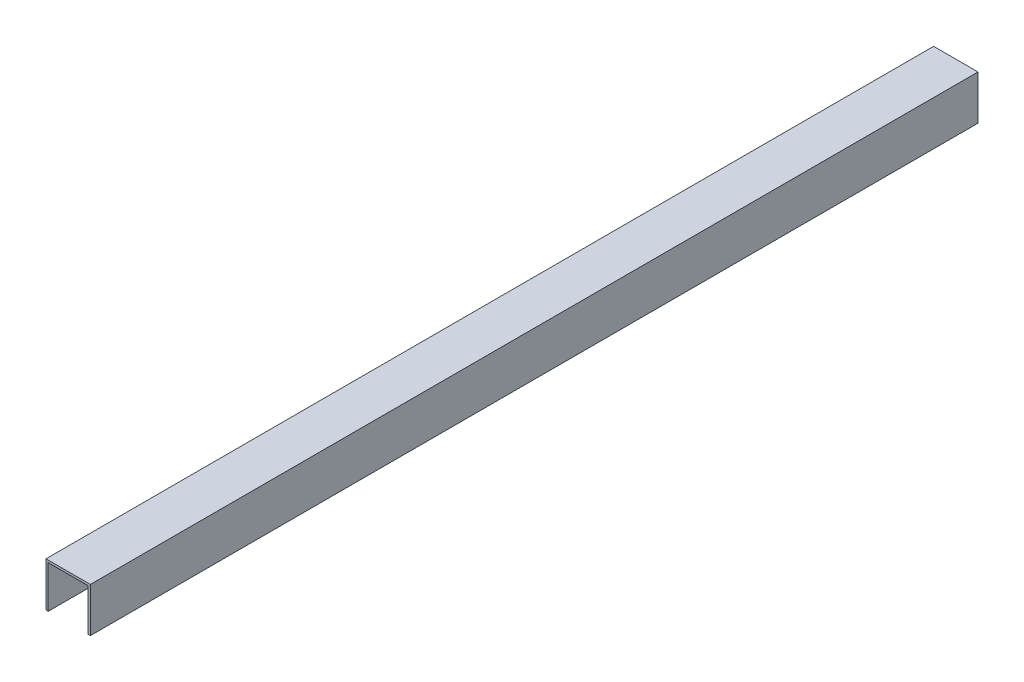
from build123d import *

# Parameters (mm, degrees)
BOSS_EXTRU_1_DEPTH = 200


with BuildPart() as part:
    # Esquisse2 → Boss.-Extru.1 (new body)
    with BuildSketch(Plane.XY):
        Polygon((-107.441493859, -9.233205108), (-107.441493859, 0.766794892), (-97.441493859, 0.766794892), (-97.441493859, -9.233205108), (-97.941493859, -9.233205108), (-97.941493859, 0.266794892), (-106.941493859, 0.266794892), (-106.941493859, -9.233205108), align=None)
    extrude(amount=BOSS_EXTRU_1_DEPTH)


solid = part.part
